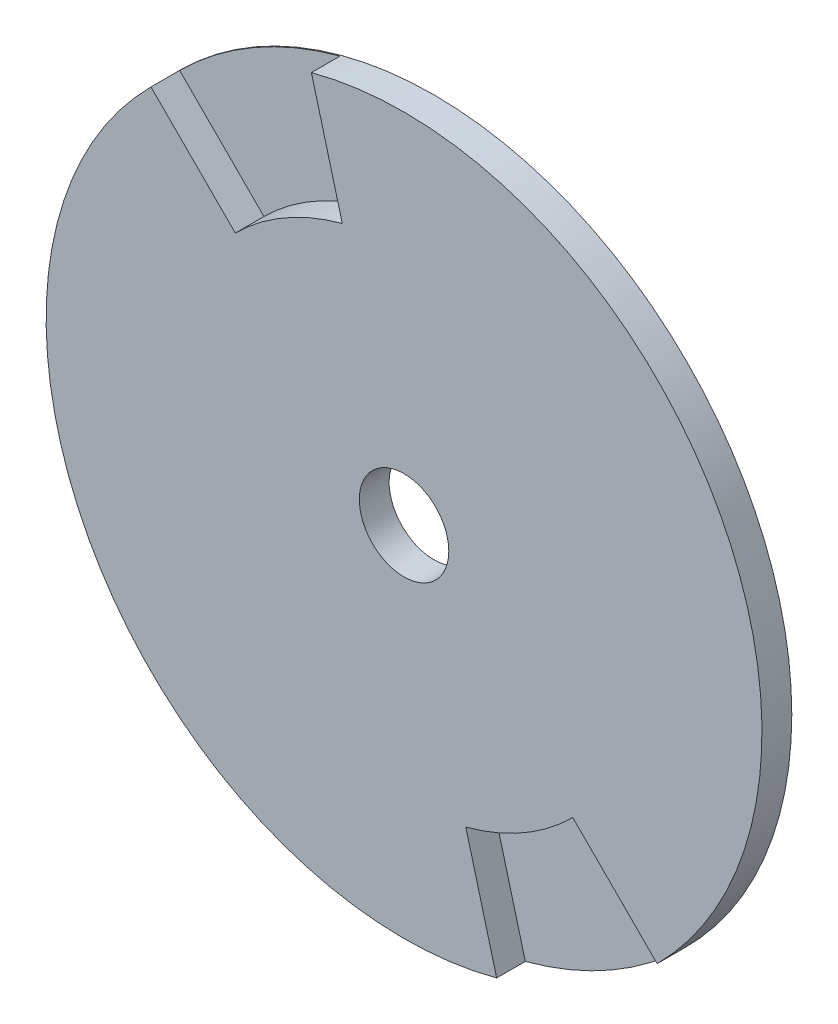
from build123d import *

# Parameters (mm, degrees)
SKETCH1_R          = 19.05
EXTRUDE1_DEPTH     = 1.5875
SKETCH2_R          = 2.38125
CUT_EXTRUDE1_DEPTH = 3.175
CUT_EXTRUDE2_DEPTH = 1.524


with BuildPart() as part:
    # Sketch1 → Extrude1 (new body)
    with BuildSketch(Plane.XY):
        Circle(SKETCH1_R)
    extrude(amount=EXTRUDE1_DEPTH)

    # Sketch2 → Cut-Extrude1 (cut)
    with BuildSketch(Plane.XY.offset(1.5875)):
        Circle(SKETCH2_R)
    extrude(amount=-CUT_EXTRUDE1_DEPTH, mode=Mode.SUBTRACT)

    # Sketch3 → Cut-Extrude2 (cut)
    with BuildSketch(Plane.XY.offset(1.5875)):
        with BuildLine():
            ThreePointArc((-4.930502809, 18.400886991), (-9.525, 16.497783942), (-13.470384182, 13.470384182))
            Line((-13.470384182, 13.470384182), (-8.980256121, 8.980256121))
            ThreePointArc((-8.980256121, 8.980256121), (-6.35, 10.998522628), (-3.287001873, 12.267257994))
            Line((-3.287001873, 12.267257994), (-4.930502809, 18.400886991))
        make_face()
        with BuildLine():
            Line((3.287001873, -12.267257994), (4.930502809, -18.400886991))
            ThreePointArc((4.930502809, -18.400886991), (9.525, -16.497783942), (13.470384182, -13.470384182))
            Line((13.470384182, -13.470384182), (8.980256121, -8.980256121))
            ThreePointArc((8.980256121, -8.980256121), (6.35, -10.998522628), (3.287001873, -12.267257994))
        make_face()
    extrude(amount=-CUT_EXTRUDE2_DEPTH, mode=Mode.SUBTRACT)


solid = part.part
